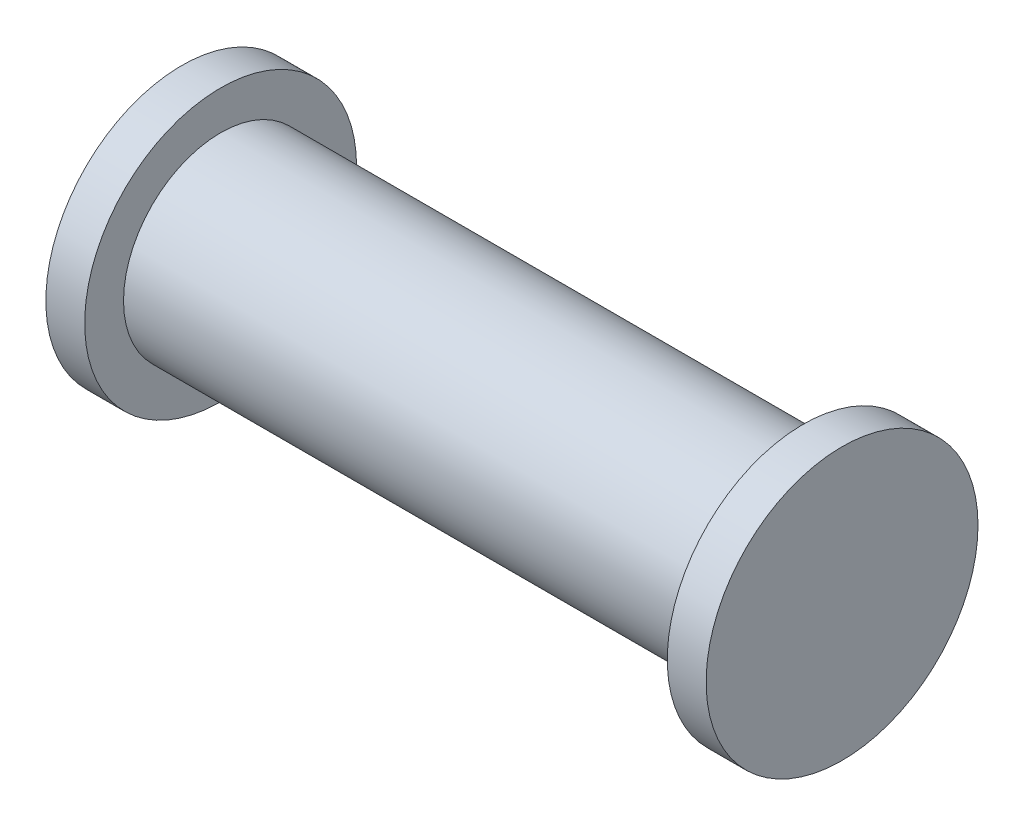
from build123d import *

# Parameters (mm, degrees)
SKETCH1_R           = 12.5
BOSS_EXTRUDE1_DEPTH = 37.5
SKETCH4_R           = 17.5
BOSS_EXTRUDE3_DEPTH = 5


with BuildPart() as part:
    # Sketch1 → Boss-Extrude1 (new, symmetric)
    with BuildSketch(Plane(origin=(0, 0, 0), x_dir=(0, 0, -1), z_dir=(1, 0, 0))):
        Circle(SKETCH1_R)
    extrude(amount=BOSS_EXTRUDE1_DEPTH, both=True)

    # Sketch4 → Boss-Extrude3 (add)
    with BuildSketch(Plane(origin=(37.5, 0, 0), x_dir=(0, 0, -1), z_dir=(1, 0, 0))):
        Circle(SKETCH4_R)
    boss_extrude3 = extrude(amount=BOSS_EXTRUDE3_DEPTH)

    # Mirror1: Boss-Extrude3 across plane
    add(boss_extrude3.mirror(Plane(origin=(0, 0, 0), x_dir=(0, 0, 1), z_dir=(1, 0, 0))))


solid = part.part
